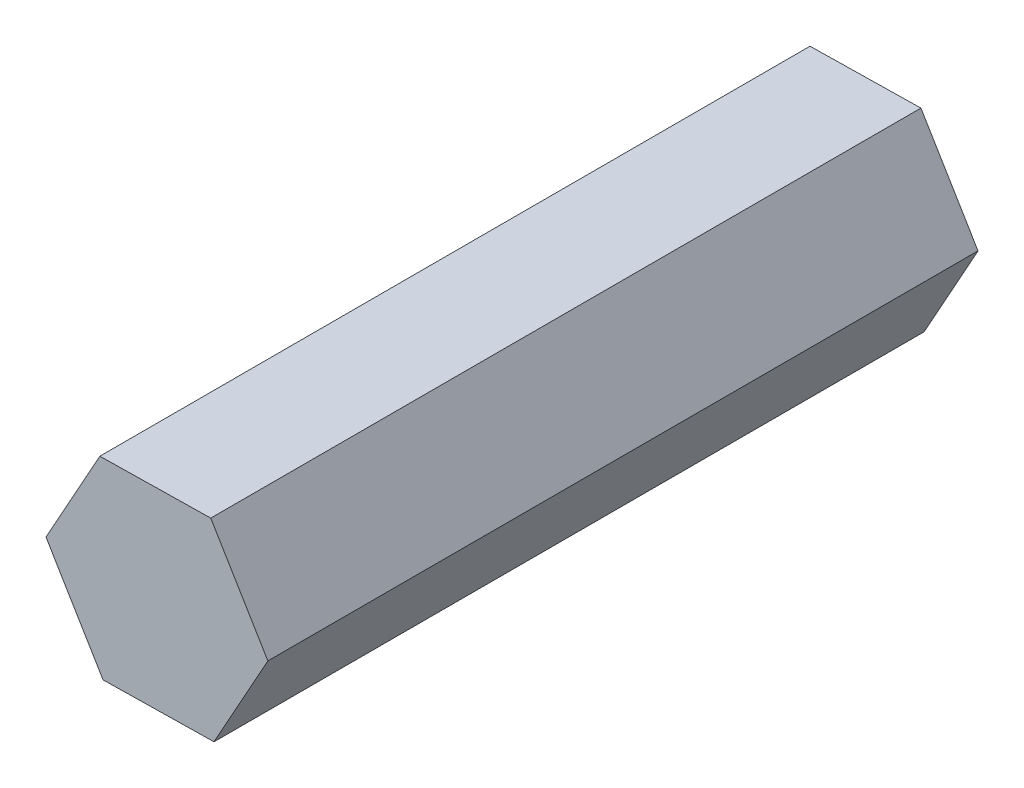
from build123d import *

# Parameters (mm, degrees)
EXTRUDE_1_DEPTH = 17


with BuildPart() as part:
    # 草图1 → 凸台-拉伸1 (new body)
    with BuildSketch(Plane.XY):
        Polygon((-2.65430906, 24.561081581), (-1.365277136, 26.883091493), (-2.731680745, 29.160430842), (-5.387116279, 29.115760279), (-6.676148203, 26.793750367), (-5.309744594, 24.516411018), align=None)
    extrude(amount=EXTRUDE_1_DEPTH)


solid = part.part
